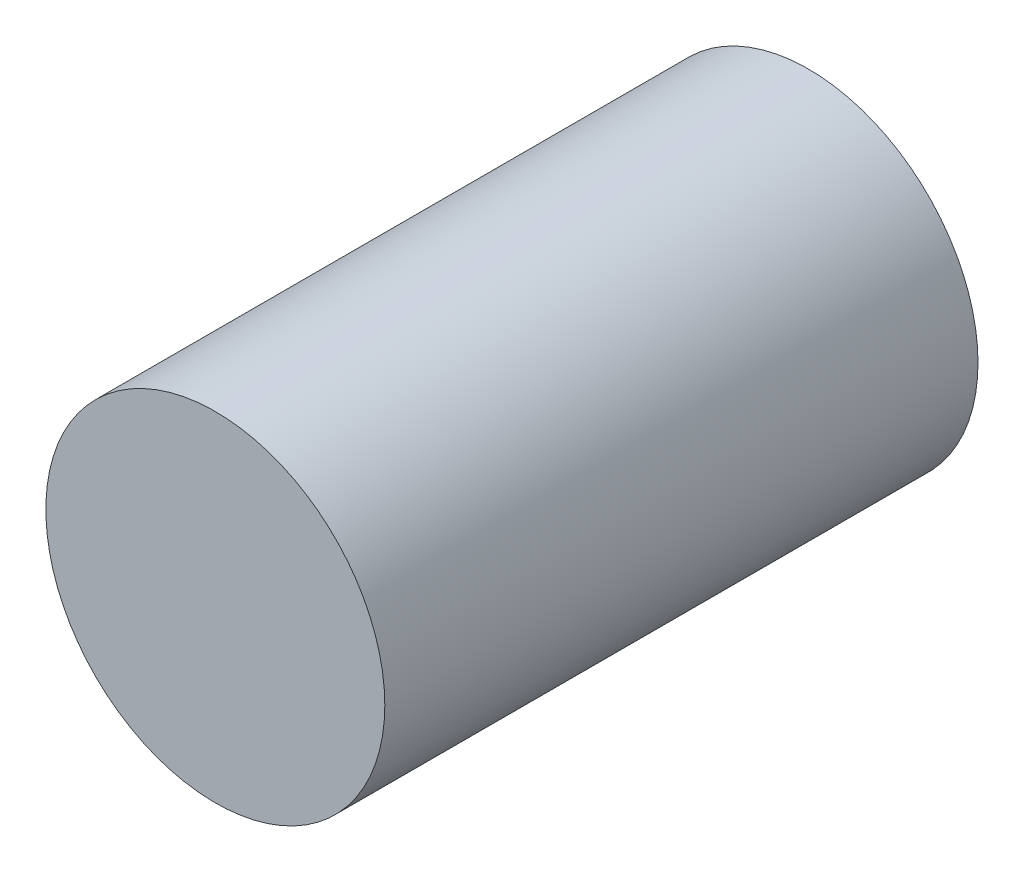
from build123d import *

# Parameters (mm, degrees)
SKETCH1_R           = 5.08
BOSS_EXTRUDE1_DEPTH = 17.78


with BuildPart() as part:
    # Sketch1 → Boss-Extrude1 (new body)
    with BuildSketch(Plane.XY):
        with Locations((-8.219288999, 0)):
            Circle(SKETCH1_R)
    extrude(amount=BOSS_EXTRUDE1_DEPTH)


solid = part.part
